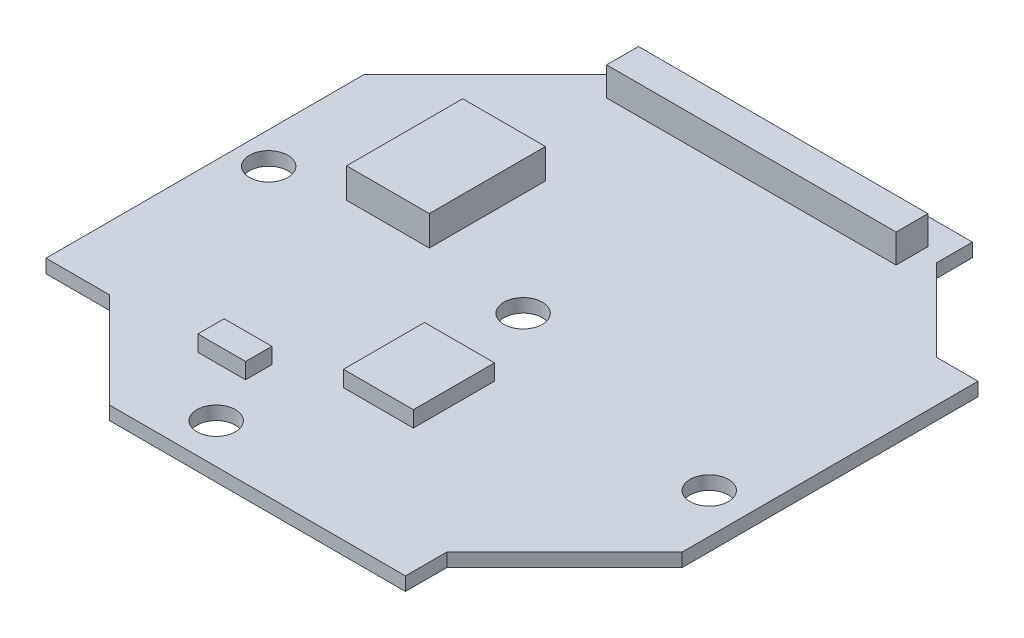
from build123d import *

# Parameters (mm, degrees)
BOSS_EXTRUDE1_DEPTH = 0.85
SKETCH2_W           = 18.2
SKETCH2_H           = 2
BOSS_EXTRUDE2_DEPTH = 1.8
SKETCH3_W           = 5.2
SKETCH3_H           = 7.3
BOSS_EXTRUDE3_DEPTH = 1.88
SKETCH4_W           = 4.4
SKETCH4_H           = 5.1
SKETCH4_W_2         = 3
SKETCH4_H_2         = 1.65
BOSS_EXTRUDE4_DEPTH = 1
SKETCH5_R           = 1.21
CUT_EXTRUDE1_DEPTH  = 1.85


with BuildPart() as part:
    # Sketch1 → Boss-Extrude1 (new body)
    with BuildSketch(Plane(origin=(0, 0, 0), x_dir=(1, 0, 0), z_dir=(0, 1, 0))):
        Polygon((-10.25, 18), (10.25, 18), (10.25, 15.75), (15.4, 10.6), (18, 10.6), (18, -8), (10.6, -15.4), (10.6, -18), (-8, -18), (-14, -12), (-18, -12), (-18, 8), (-10.25, 15.75), align=None)
    extrude(amount=BOSS_EXTRUDE1_DEPTH)

    # Sketch2 → Boss-Extrude2 (add)
    with BuildSketch(Plane(origin=(0, 0.85, 0), x_dir=(1, 0, 0), z_dir=(0, 1, 0))):
        with Locations((0, 15.35)):
            Rectangle(SKETCH2_W, SKETCH2_H)
    extrude(amount=BOSS_EXTRUDE2_DEPTH)

    # Sketch3 → Boss-Extrude3 (add)
    with BuildSketch(Plane(origin=(0, 0.85, 0), x_dir=(1, 0, 0), z_dir=(0, 1, 0))):
        with Locations((-9.1, 4.25)):
            Rectangle(SKETCH3_W, SKETCH3_H)
    extrude(amount=BOSS_EXTRUDE3_DEPTH)

    # Sketch4 → Boss-Extrude4 (add)
    with BuildSketch(Plane(origin=(0, 0.85, 0), x_dir=(1, 0, 0), z_dir=(0, 1, 0))):
        with Locations((0.6, -7.15)):
            Rectangle(SKETCH4_W, SKETCH4_H)
        with Locations((-6.6, -11.525)):
            Rectangle(SKETCH4_W_2, SKETCH4_H_2)
    extrude(amount=BOSS_EXTRUDE4_DEPTH)

    # Sketch5 → Cut-Extrude1 (cut, through all)
    with BuildSketch(Plane(origin=(0, 0.85, 0), x_dir=(1, 0, 0), z_dir=(0, 1, 0))):
        Circle(SKETCH5_R)
        with Locations((-16, 0)):
            Circle(SKETCH5_R)
        with Locations((-3.8, -15.5)):
            Circle(SKETCH5_R)
        with Locations((15.5, -3.8)):
            Circle(SKETCH5_R)
    extrude(amount=-CUT_EXTRUDE1_DEPTH, mode=Mode.SUBTRACT)


solid = part.part
